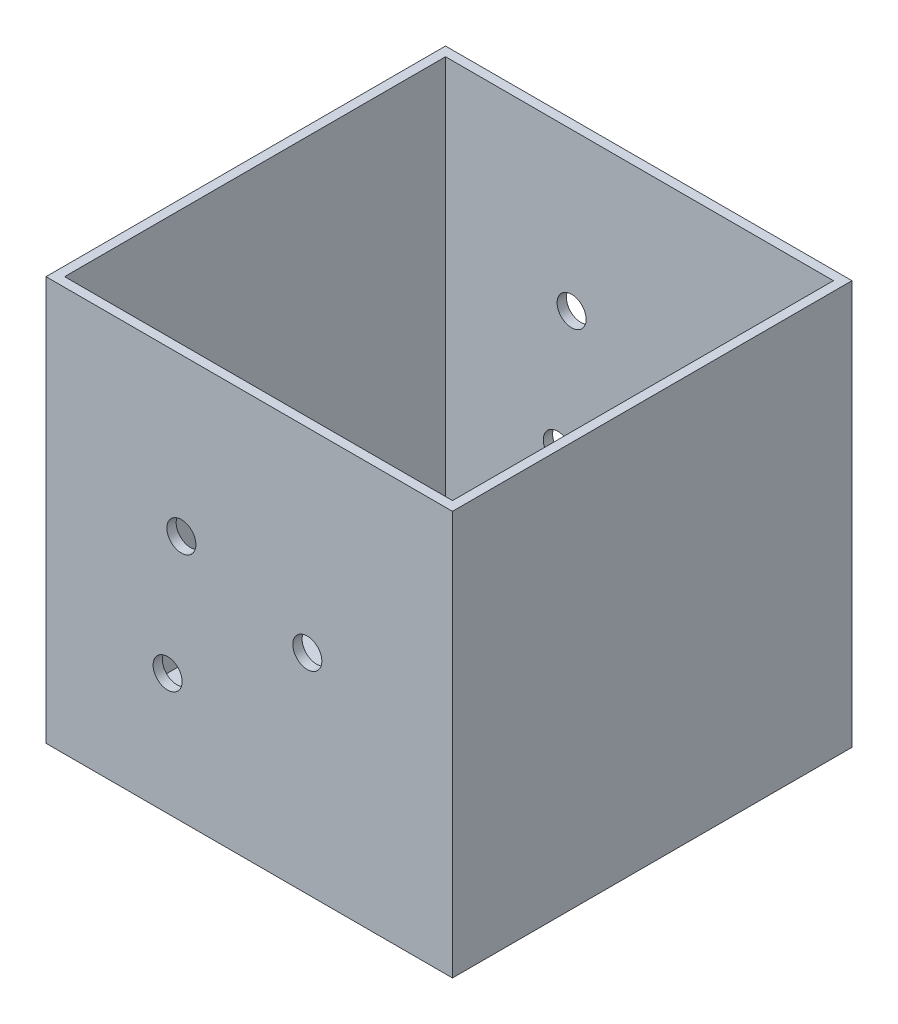
from build123d import *

# Parameters (mm, degrees)
IZIM1_W                     = 350
IZIM1_H                     = 348
IZIM1_R                     = 12.5
Y_KSEKLIK_EKSTR_ZYON4_DEPTH = 344
BO_ALTMA2_T                 = -8


with BuildPart() as part:
    # Çizim1 → Yükseklik-Ekstrüzyon4 (new body)
    with BuildSketch(Plane.XY):
        with Locations((-50, -6)):
            Rectangle(IZIM1_W, IZIM1_H)
        Circle(IZIM1_R, mode=Mode.SUBTRACT)
        with Locations((-108.440540321, 32.652897497)):
            Circle(IZIM1_R, mode=Mode.SUBTRACT)
        with Locations((-120.297461902, -75.448794953)):
            Circle(IZIM1_R, mode=Mode.SUBTRACT)
    extrude(amount=-Y_KSEKLIK_EKSTR_ZYON4_DEPTH)

    # İç Boşaltma2
    bo_altma2_openings = [part.faces().sort_by_distance(p)[0] for p in [
        (12.5, 0, -344),
        (-50, 168, -172),
        (-107.797461902, -75.448794953, -344),
        (-95.940540321, 32.652897497, -344),
    ]]
    offset(amount=BO_ALTMA2_T, openings=bo_altma2_openings, kind=Kind.INTERSECTION)


solid = part.part
